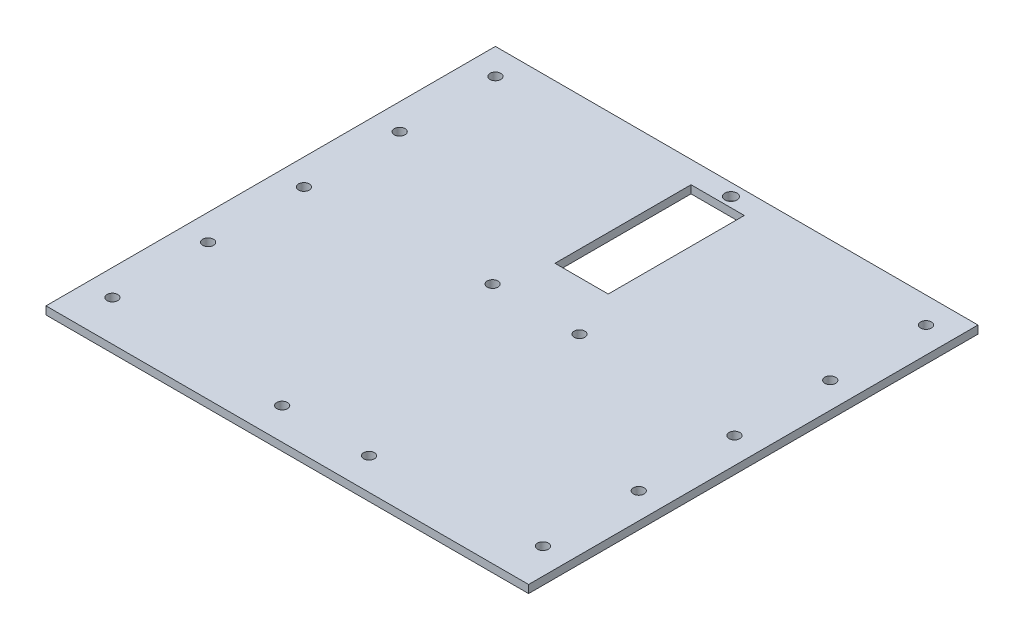
from build123d import *

# Parameters (mm, degrees)
SKETCH1_W           = 193.294
SKETCH1_H           = 180
BOSS_EXTRUDE1_DEPTH = 3.175
SKETCH2_R           = 2.159
CUT_EXTRUDE1_DEPTH  = 4.175
SKETCH3_R           = 2.159
SKETCH3_R_2         = 2.415341229
CUT_EXTRUDE2_DEPTH  = 4.175
SKETCH4_W           = 21.330448395
SKETCH4_H           = 54.500274109
CUT_EXTRUDE3_DEPTH  = 4.175


with BuildPart() as part:
    # Sketch1 → Boss-Extrude1 (new body)
    with BuildSketch(Plane(origin=(0, 0, 0), x_dir=(1, 0, 0), z_dir=(0, 1, 0))):
        Rectangle(SKETCH1_W, SKETCH1_H)
    extrude(amount=BOSS_EXTRUDE1_DEPTH)

    # Sketch2 → Cut-Extrude1 (cut, through all)
    with BuildSketch(Plane(origin=(0, 3.175, 0), x_dir=(1, 0, 0), z_dir=(0, 1, 0))):
        with Locations((-86.233, 79.586)):
            Circle(SKETCH2_R)
        with Locations((86.233, 79.586)):
            Circle(SKETCH2_R)
        with Locations((86.233, 41.232)):
            Circle(SKETCH2_R)
        with Locations((86.233, 2.878)):
            Circle(SKETCH2_R)
        with Locations((86.233, -35.476)):
            Circle(SKETCH2_R)
        with Locations((-86.233, 41.232)):
            Circle(SKETCH2_R)
        with Locations((-86.233, 2.878)):
            Circle(SKETCH2_R)
        with Locations((-86.233, -35.476)):
            Circle(SKETCH2_R)
        with Locations((-86.233, -73.83)):
            Circle(SKETCH2_R)
        with Locations((86.233, -73.83)):
            Circle(SKETCH2_R)
    extrude(amount=-CUT_EXTRUDE1_DEPTH, mode=Mode.SUBTRACT)

    # Sketch3 → Cut-Extrude2 (cut, through all)
    with BuildSketch(Plane(origin=(0, 3.175, 0), x_dir=(1, 0, 0), z_dir=(0, 1, 0))):
        with Locations((-14.76439348, 7.002233071)):
            Circle(SKETCH3_R)
        with Locations((20.03360652, 7.002233071)):
            Circle(SKETCH3_R)
        with Locations((20.03360652, -77.3)):
            Circle(SKETCH3_R)
        with Locations((-14.76439348, -77.3)):
            Circle(SKETCH3_R)
        with Locations((2.60360652, 85.080051335)):
            Circle(SKETCH3_R_2)
    extrude(amount=-CUT_EXTRUDE2_DEPTH, mode=Mode.SUBTRACT)

    # Sketch4 → Cut-Extrude3 (cut, through all)
    with BuildSketch(Plane(origin=(0, 3.175, 0), x_dir=(1, 0, 0), z_dir=(0, 1, 0))):
        with Locations((1.186420924, 53.941345115)):
            Rectangle(SKETCH4_W, SKETCH4_H)
    extrude(amount=-CUT_EXTRUDE3_DEPTH, mode=Mode.SUBTRACT)


solid = part.part
